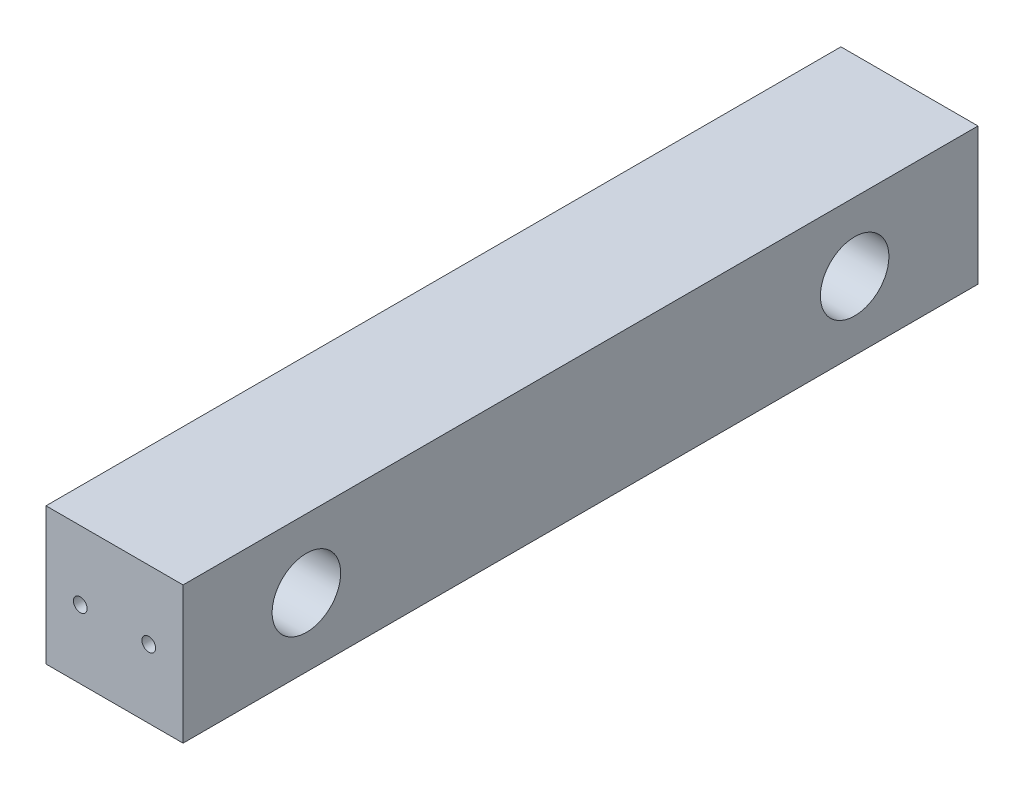
from build123d import *

# Parameters (mm, degrees)
SKETCH1_W           = 20
SKETCH1_H           = 20
BOSS_EXTRUDE1_DEPTH = 116
SKETCH1_5_R         = 1
CUT_EXTRUDE1_DEPTH  = 10
CUT_EXTRUDE2_START  = -10
SKETCH4_R           = 1
CUT_EXTRUDE2_DEPTH  = 10
SKETCH5_R           = 2.5
CUT_EXTRUDE3_DEPTH  = 120.398492453
SKETCH6_R           = 5
CUT_EXTRUDE4_DEPTH  = 10


with BuildPart() as part:
    # Sketch1 → Boss-Extrude1 (new body)
    with BuildSketch(Plane.XY):
        with Locations((10, 10)):
            Rectangle(SKETCH1_W, SKETCH1_H)
    extrude(amount=BOSS_EXTRUDE1_DEPTH)

    # Sketch1_5 → Cut-Extrude1 (cut)
    with BuildSketch(Plane.XY):
        with Locations((15, 10)):
            Circle(SKETCH1_5_R)
        with Locations((5, 10)):
            Circle(SKETCH1_5_R)
    extrude(amount=CUT_EXTRUDE1_DEPTH, mode=Mode.SUBTRACT)

    # Sketch4 → Cut-Extrude2 (cut)
    with BuildSketch(Plane.XY.offset(116).offset(CUT_EXTRUDE2_START)):
        with Locations((5, 10)):
            Circle(SKETCH4_R)
        with Locations((15, 10)):
            Circle(SKETCH4_R)
    extrude(amount=CUT_EXTRUDE2_DEPTH, mode=Mode.SUBTRACT)

    # Sketch5 → Cut-Extrude3 (cut, through all)
    with BuildSketch(Plane(origin=(20, 0, 0), x_dir=(0, 0, -1), z_dir=(1, 0, 0))):
        with Locations((-98, 10)):
            Circle(SKETCH5_R)
        with Locations((-18, 10)):
            Circle(SKETCH5_R)
    extrude(amount=-CUT_EXTRUDE3_DEPTH, mode=Mode.SUBTRACT)

    # Sketch6 → Cut-Extrude4 (cut)
    with BuildSketch(Plane(origin=(20, 0, 0), x_dir=(0, 0, -1), z_dir=(1, 0, 0))):
        with Locations((-98, 10)):
            Circle(SKETCH6_R)
        with Locations((-18, 10)):
            Circle(SKETCH6_R)
    extrude(amount=-CUT_EXTRUDE4_DEPTH, mode=Mode.SUBTRACT)


solid = part.part
